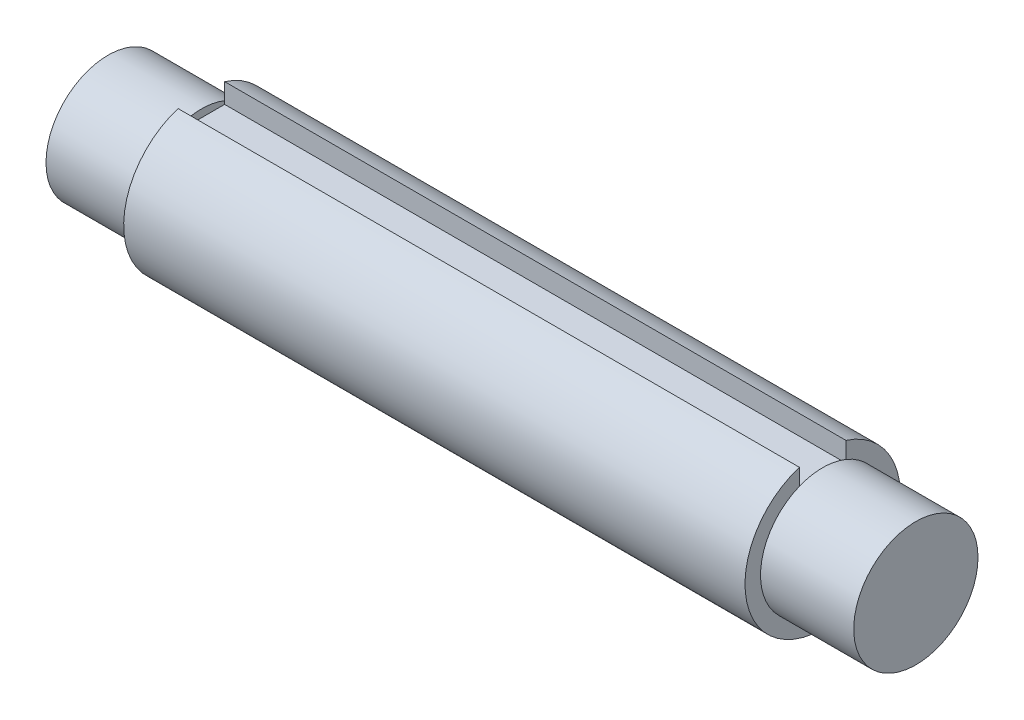
from build123d import *

# Parameters (mm, degrees)
SKETCH1_R           = 7.9375
BOSS_EXTRUDE1_DEPTH = 41.275
SKETCH4_OUTSIDE_W   = 34.984
SKETCH4_OUTSIDE_H   = 34.984
SKETCH4_OUTSIDE_R   = 6.35
CUT_EXTRUDE1_DEPTH  = 9.525
SKETCH5_OUTSIDE_W   = 34.984
SKETCH5_OUTSIDE_H   = 34.984
SKETCH5_OUTSIDE_R   = 6.35
CUT_EXTRUDE2_DEPTH  = 9.525
CUT_EXTRUDE3_DEPTH  = 63.5


with BuildPart() as part:
    # Sketch1 → Boss-Extrude1 (new body, symmetric)
    with BuildSketch(Plane(origin=(0, 0, 0), x_dir=(0, 0, -1), z_dir=(1, 0, 0))):
        Circle(SKETCH1_R)
    extrude(amount=BOSS_EXTRUDE1_DEPTH, both=True)

    # Sketch4 outside → Cut-Extrude1 (cut)
    with BuildSketch(Plane(origin=(41.275, 0, 0), x_dir=(0, 0, -1), z_dir=(1, 0, 0))):
        Rectangle(SKETCH4_OUTSIDE_W, SKETCH4_OUTSIDE_H)
        Circle(SKETCH4_OUTSIDE_R, mode=Mode.SUBTRACT)
    extrude(amount=-CUT_EXTRUDE1_DEPTH, mode=Mode.SUBTRACT)

    # Sketch5 outside → Cut-Extrude2 (cut)
    with BuildSketch(Plane.ZY.offset(41.275)):
        Rectangle(SKETCH5_OUTSIDE_W, SKETCH5_OUTSIDE_H)
        with Locations(Location((0, 0, 0), (0, 0, 180))):  # turned: the seam where the file's is
            Circle(SKETCH5_OUTSIDE_R, mode=Mode.SUBTRACT)
    extrude(amount=-CUT_EXTRUDE2_DEPTH, mode=Mode.SUBTRACT)

    # Sketch7 → Cut-Extrude3 (cut)
    with BuildSketch(Plane.ZY.offset(31.75)):
        with BuildLine():
            Line((0, 5.55625), (2.38125, 5.55625))
            Line((2.38125, 5.55625), (2.38125, 7.571892411))
            ThreePointArc((2.38125, 7.571892411), (0, 7.9375), (-2.38125, 7.571892411))
            Line((-2.38125, 7.571892411), (-2.38125, 5.55625))
            Line((-2.38125, 5.55625), (0, 5.55625))
        make_face()
    extrude(amount=-CUT_EXTRUDE3_DEPTH, mode=Mode.SUBTRACT)


solid = part.part
